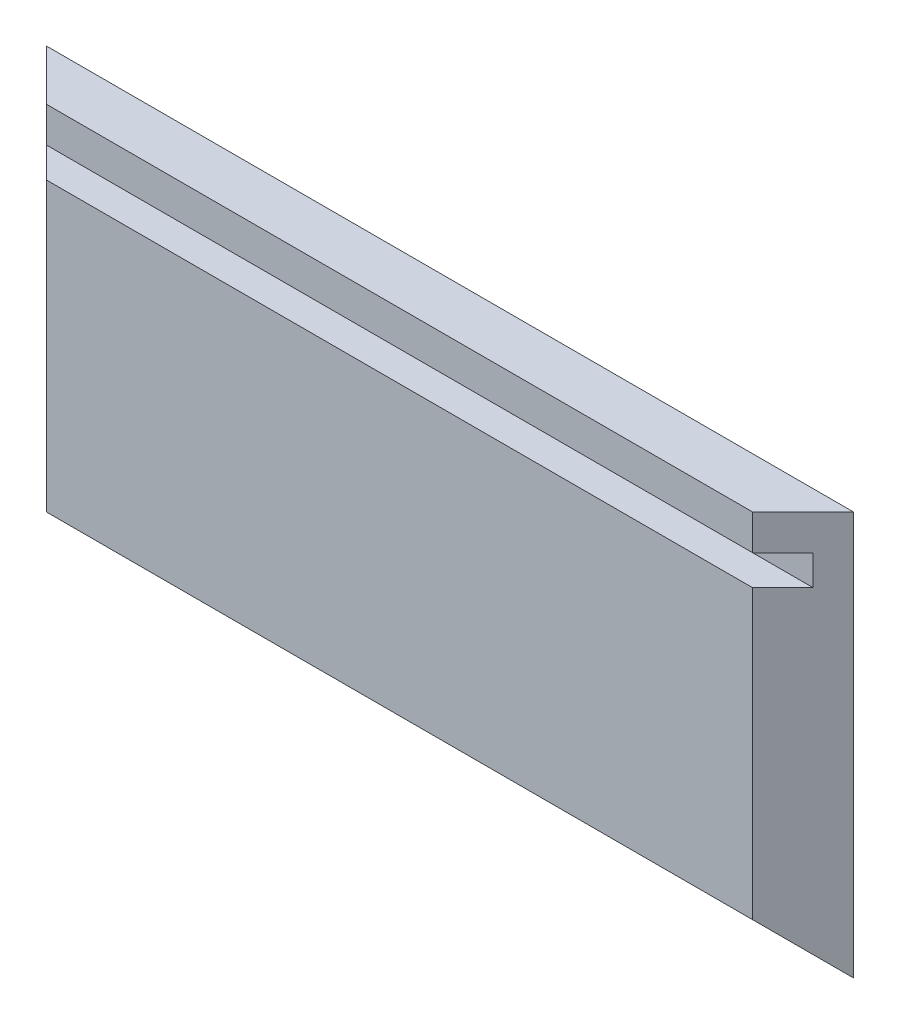
from build123d import *

# Parameters (mm, degrees)
BOSS_EXTRUDE2_DEPTH     = 40
CUT_EXTRUDE1_DEPTH      = 41
CUT_EXTRUDE1_DEPTH_BACK = 41
SKETCH7_W               = 3
SKETCH7_H               = 3
CUT_EXTRUDE2_DEPTH      = 41
CUT_EXTRUDE2_DEPTH_BACK = 41


with BuildPart() as part:
    # Sketch3 → Boss-Extrude2 (new body)
    with BuildSketch(Plane(origin=(0, 0, 0), x_dir=(1, 0, 0), z_dir=(0, 1, 0))):
        Polygon((-40, 2.5), (-35, -2.5), (35, -2.5), (40, 2.5), align=None)
    extrude(amount=BOSS_EXTRUDE2_DEPTH)

    # Sketch4 → Cut-Extrude1 (cut, two sides)
    with BuildSketch(Plane(origin=(0, 0, 0), x_dir=(0, 0, -1), z_dir=(1, 0, 0))) as cut_extrude1_sk:
        Polygon((-2.5, 0), (2.5, 0), (-2.5, 5), align=None)
    extrude(amount=CUT_EXTRUDE1_DEPTH, mode=Mode.SUBTRACT)
    extrude(cut_extrude1_sk.sketch, amount=-CUT_EXTRUDE1_DEPTH_BACK, mode=Mode.SUBTRACT)

    # Sketch7 → Cut-Extrude2 (cut, two sides)
    with BuildSketch(Plane(origin=(0, 0, 0), x_dir=(0, 0, -1), z_dir=(1, 0, 0))) as cut_extrude2_sk:
        with Locations((-1, 35)):
            Rectangle(SKETCH7_W, SKETCH7_H)
    extrude(amount=CUT_EXTRUDE2_DEPTH, mode=Mode.SUBTRACT)
    extrude(cut_extrude2_sk.sketch, amount=-CUT_EXTRUDE2_DEPTH_BACK, mode=Mode.SUBTRACT)


solid = part.part
